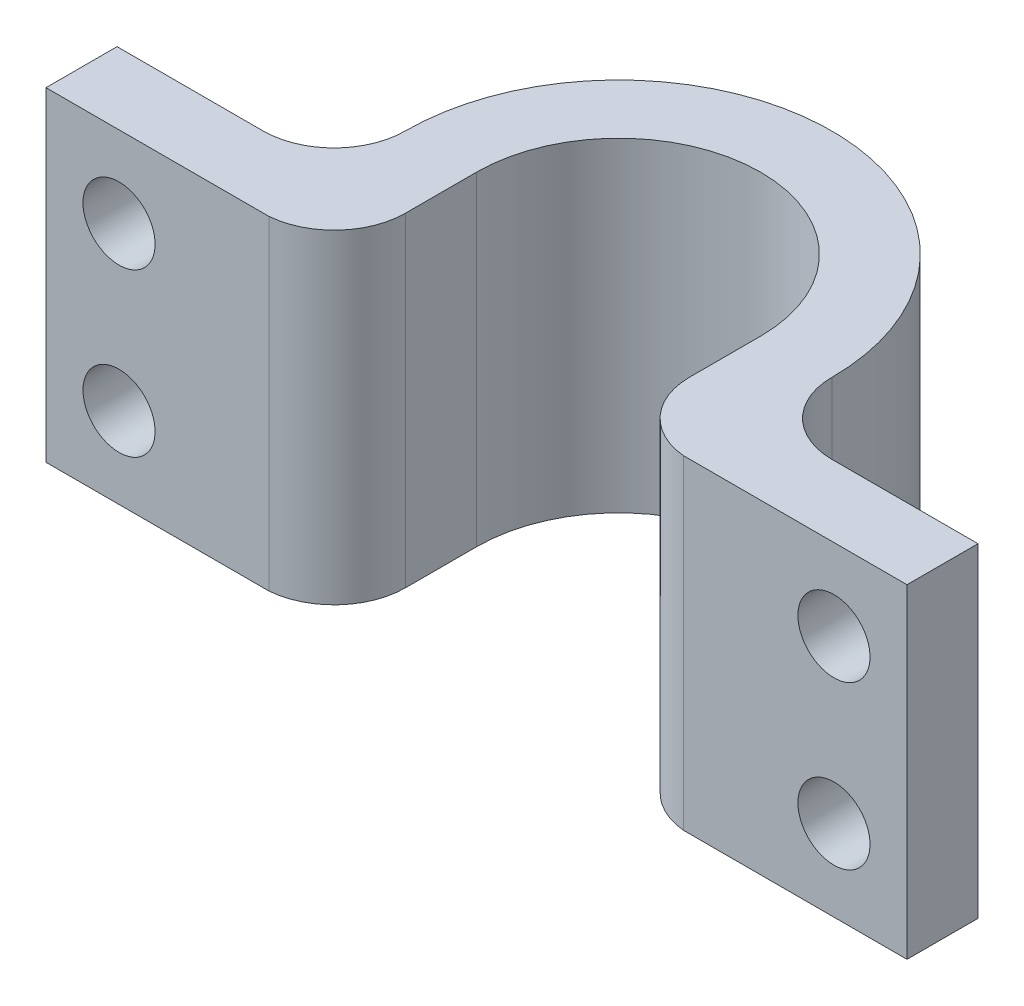
from build123d import *

# Parameters (mm, degrees)
Y_KSEKLIK_EKSTR_ZYON1_DEPTH = 9
IZIM2_R                     = 1
KES_EKSTR_ZYON1_DEPTH       = 9
L_EK1_SCALE                 = 0.5


with BuildPart() as part:
    # Çizim1 → Yükseklik-Ekstrüzyon1 (new body)
    with BuildSketch(Plane(origin=(0, 0, 0), x_dir=(1, 0, 0), z_dir=(0, 1, 0))):
        with BuildLine():
            Line((3.94, 0), (3.94, -1.970806212))
            ThreePointArc((3.94, -1.970806212), (4.455977206, -3.302963323), (5.734671586, -3.94))
            Line((5.734671586, -3.94), (11.94, -3.94))
            Line((11.94, -3.94), (11.94, -1.970806212))
            Line((11.94, -1.970806212), (7.888485675, -1.970806212))
            ThreePointArc((7.888485675, -1.970806212), (6.494915238, -1.393570437), (5.917679463, 0))
            ThreePointArc((5.917679463, 0), (0, 5.917679463), (-5.917679463, 0))
            ThreePointArc((-5.917679463, 0), (-6.494915238, -1.393570437), (-7.888485675, -1.970806212))
            Line((-7.888485675, -1.970806212), (-11.94, -1.970806212))
            Line((-11.94, -1.970806212), (-11.94, -3.941612423))
            Line((-11.94, -3.941612423), (-5.752940471, -3.941612423))
            ThreePointArc((-5.752940471, -3.941612423), (-4.462169762, -3.309726511), (-3.94, -1.970806212))
            Line((-3.94, -1.970806212), (-3.94, 0))
            ThreePointArc((-3.94, 0), (0, 3.94), (3.94, 0))
        make_face()
    extrude(amount=Y_KSEKLIK_EKSTR_ZYON1_DEPTH)

    # Çizim2 → Kes-Ekstrüzyon1 (cut)
    with BuildSketch(Plane(origin=(0, 0, 1.970806212), x_dir=(-1, 0, 0), z_dir=(0, 0, -1))):
        with Locations((-9.914242837, 6.75)):
            Circle(IZIM2_R)
        with Locations((-9.914242837, 2.25)):
            Circle(IZIM2_R)
        with Locations((9.914242837, 2.25)):
            Circle(IZIM2_R)
        with Locations((9.914242837, 6.75)):
            Circle(IZIM2_R)
    extrude(amount=-KES_EKSTR_ZYON1_DEPTH, mode=Mode.SUBTRACT)


with BuildPart() as part_1:
    # Ölçek1: scaled about (-0.001148425, 4.5, -0.117296344)
    add(part.part.scale(L_EK1_SCALE).moved(Location((-0.000574213, 2.25, -0.058648172))))


solid = part_1.part
